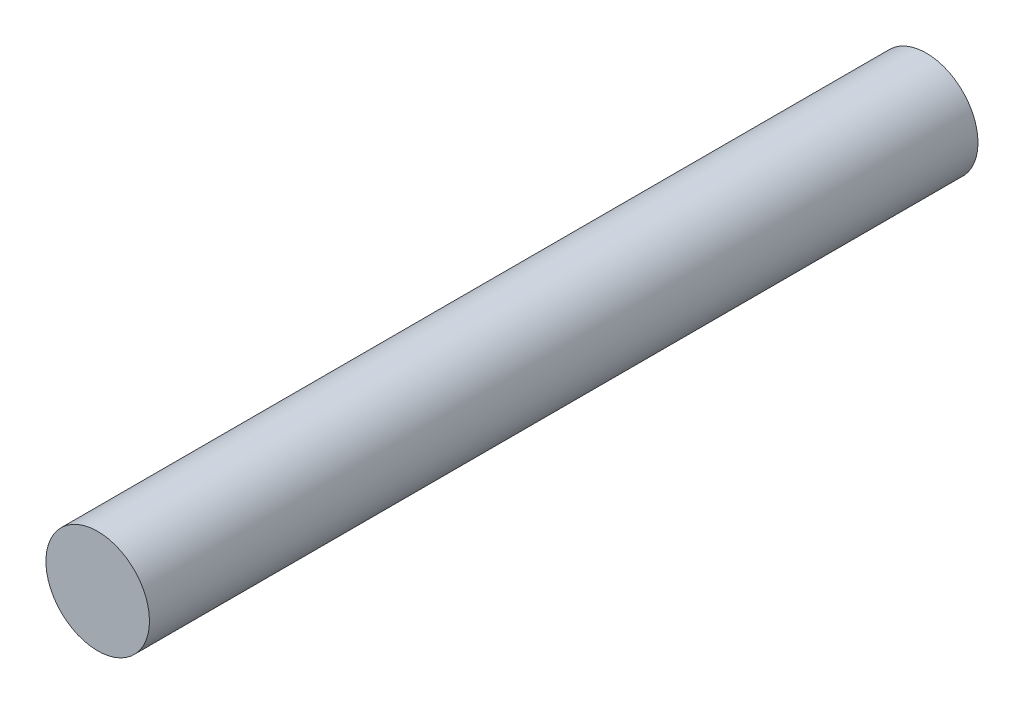
from build123d import *

# Parameters (mm, degrees)
SKETCH_1_R      = 2.5
EXTRUDE_1_DEPTH = 40


with BuildPart() as part:
    # Эскиз1 → Бобышка-Вытянуть1 (new body)
    with BuildSketch(Plane.XY):
        Circle(SKETCH_1_R)
    extrude(amount=EXTRUDE_1_DEPTH)


solid = part.part
